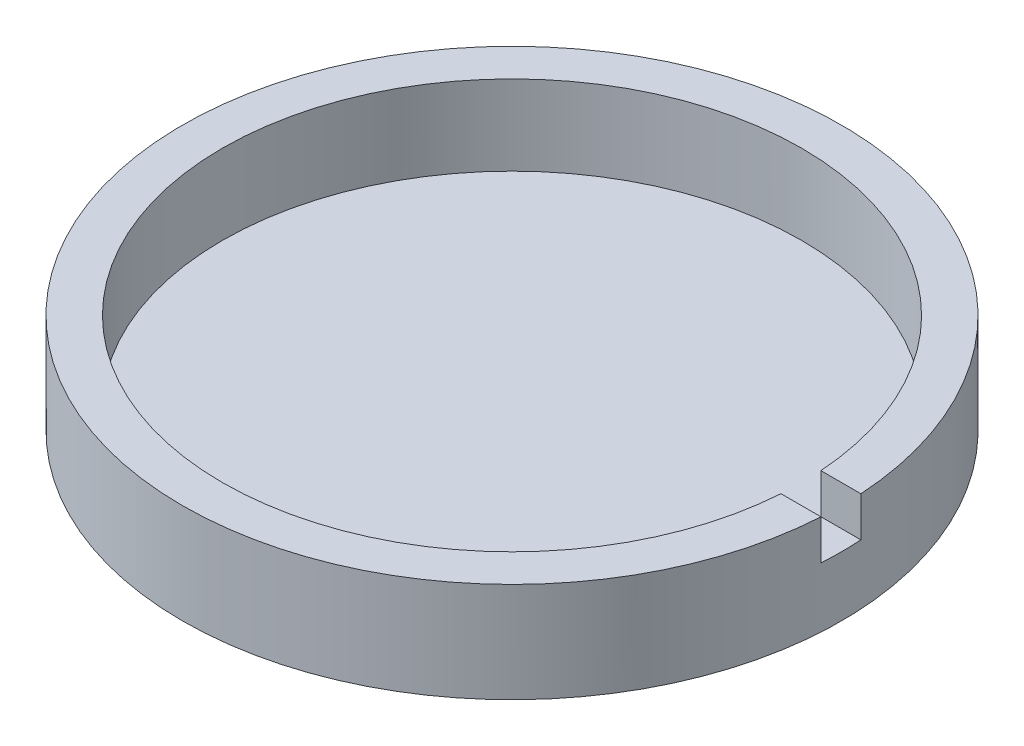
from build123d import *

# Parameters (mm, degrees)
SKETCH_2_W          = 2.034523859
SKETCH_2_H          = 2
CUT_EXTRUDE_1_DEPTH = 2


with BuildPart() as part:
    # Эскиз1 → Повернуть1 (revolve)
    with BuildSketch(Plane(origin=(0, 0, 0), x_dir=(0, 0, -1), z_dir=(1, 0, 0))):
        Polygon((0, 0), (16.5, 0), (16.5, 5), (14.5, 5), (14.5, 1), (0, 1), align=None)
    revolve(axis=Axis((0, 1, 0), (0, -1, 0)))

    # Эскиз2 → Вырез-Вытянуть1 (cut)
    with BuildSketch(Plane(origin=(0, 5, 0), x_dir=(1, 0, 0), z_dir=(0, 1, 0))):
        with Locations((15.482738071, 0)):
            Rectangle(SKETCH_2_W, SKETCH_2_H)
    extrude(amount=-CUT_EXTRUDE_1_DEPTH, mode=Mode.SUBTRACT)


solid = part.part
